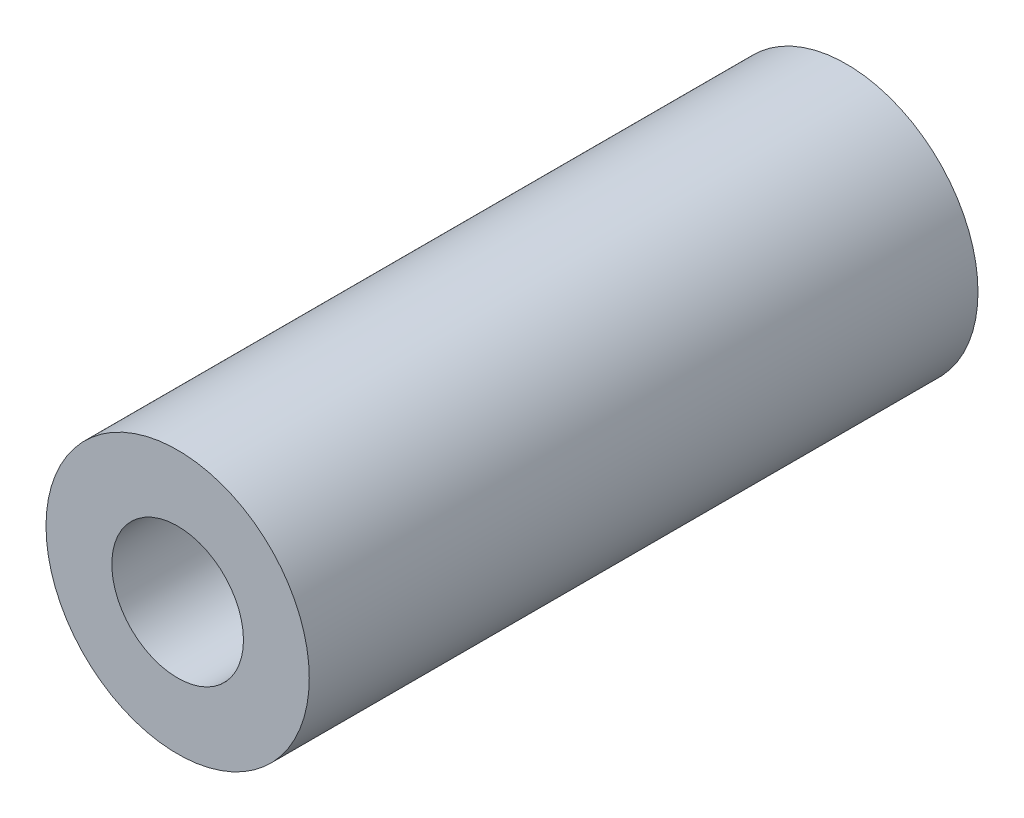
from build123d import *

# Parameters (mm, degrees)
SKETCH1_R           = 6.35
SKETCH1_R_2         = 3.175
BOSS_EXTRUDE1_DEPTH = 32.258


with BuildPart() as part:
    # Sketch1 → Boss-Extrude1 (new body)
    with BuildSketch(Plane.XY):
        Circle(SKETCH1_R)
        Circle(SKETCH1_R_2, mode=Mode.SUBTRACT)
    extrude(amount=BOSS_EXTRUDE1_DEPTH)


solid = part.part
